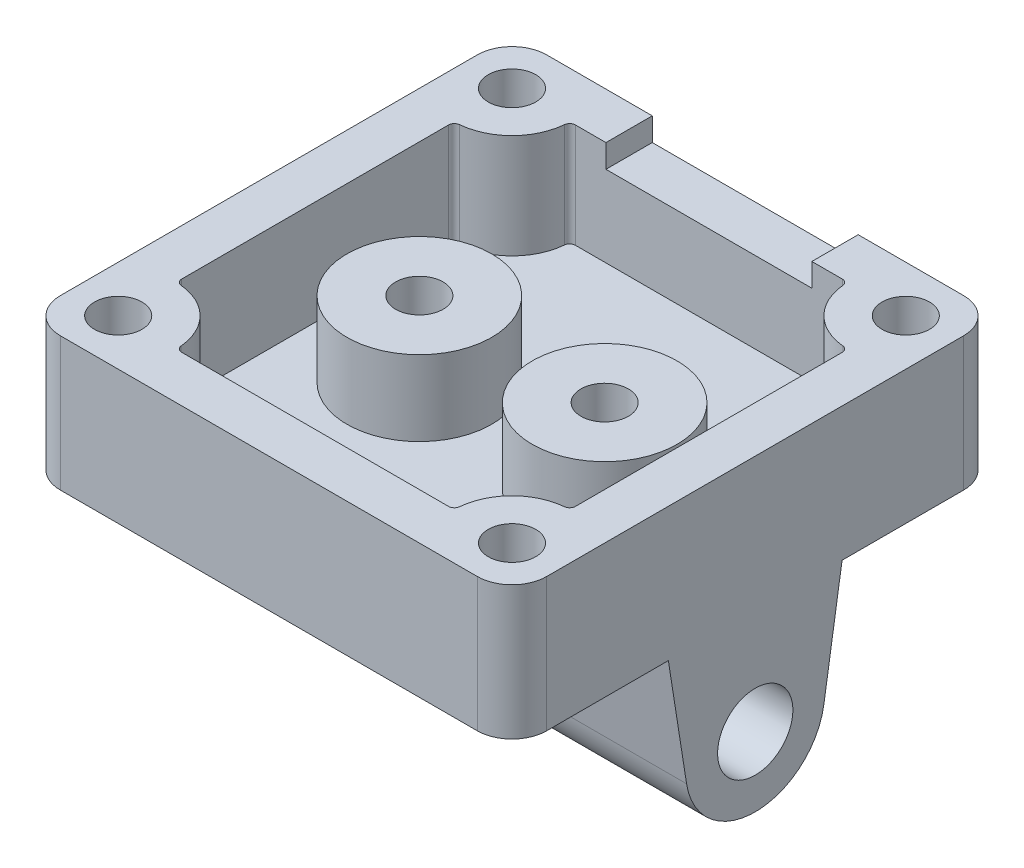
from build123d import *

# Parameters (mm, degrees)
SKETCH1_W           = 42
SKETCH1_H           = 42
BOSS_EXTRUDE1_DEPTH = 2.54
SKETCH2_W           = 42
SKETCH2_H           = 42
BOSS_EXTRUDE2_DEPTH = 9
SKETCH4_R           = 3.25
BOSS_EXTRUDE4_DEPTH = 42
SKETCH9_R           = 6.25
SKETCH9_R_2         = 2.05
BOSS_EXTRUDE5_DEPTH = 6.5
SKETCH10_R          = 2.05
CUT_EXTRUDE1_DEPTH  = 8
SKETCH12_W          = 17.78
SKETCH12_H          = 2
CUT_EXTRUDE2_DEPTH  = 4
FILLET1_R           = 3


with BuildPart() as part:
    # Sketch1 → Boss-Extrude1 (new body)
    with BuildSketch(Plane(origin=(0, 0, 0), x_dir=(1, 0, 0), z_dir=(0, 1, 0))):
        Rectangle(SKETCH1_W, SKETCH1_H)
    extrude(amount=BOSS_EXTRUDE1_DEPTH)

    # Sketch2 → Boss-Extrude2 (add)
    with BuildSketch(Plane(origin=(0, 2.54, 0), x_dir=(1, 0, 0), z_dir=(0, 1, 0))):
        Rectangle(SKETCH2_W, SKETCH2_H)
        with BuildLine():
            Line((-17, 11.522774425), (-17, -11.522774425))
            ThreePointArc((-17, -11.522774425), (-16.869274473, -11.859874356), (-16.545454545, -12.020704023))
            ThreePointArc((-16.545454545, -12.020704023), (-13.464466094, -13.464466094), (-12.020704023, -16.545454545))
            ThreePointArc((-12.020704023, -16.545454545), (-11.859874356, -16.869274473), (-11.522774425, -17))
            Line((-11.522774425, -17), (11.522774425, -17))
            ThreePointArc((11.522774425, -17), (11.859874356, -16.869274473), (12.020704023, -16.545454545))
            ThreePointArc((12.020704023, -16.545454545), (13.464466094, -13.464466094), (16.545454545, -12.020704023))
            ThreePointArc((16.545454545, -12.020704023), (16.869274473, -11.859874356), (17, -11.522774425))
            Line((17, -11.522774425), (17, 11.522774425))
            ThreePointArc((17, 11.522774425), (16.869274473, 11.859874356), (16.545454545, 12.020704023))
            ThreePointArc((16.545454545, 12.020704023), (13.464466094, 13.464466094), (12.020704023, 16.545454545))
            ThreePointArc((12.020704023, 16.545454545), (11.859874356, 16.869274473), (11.522774425, 17))
            Line((11.522774425, 17), (-11.522774425, 17))
            ThreePointArc((-11.522774425, 17), (-11.859874356, 16.869274473), (-12.020704023, 16.545454545))
            ThreePointArc((-12.020704023, 16.545454545), (-13.464466094, 13.464466094), (-16.545454545, 12.020704023))
            ThreePointArc((-16.545454545, 12.020704023), (-16.869274473, 11.859874356), (-17, 11.522774425))
        make_face(mode=Mode.SUBTRACT)
    extrude(amount=BOSS_EXTRUDE2_DEPTH)

    # Sketch4 → Boss-Extrude4 (add)
    with BuildSketch(Plane.ZY.offset(21)):
        with BuildLine():
            Line((7.5, 0), (5.927131841, -10))
            ThreePointArc((5.927131841, -10), (0, -15.067740305), (-5.927131841, -10))
            Line((-5.927131841, -10), (-7.5, 0))
            Line((-7.5, 0), (7.5, 0))
        make_face()
        with Locations((0, -9.067740305)):
            Circle(SKETCH4_R, mode=Mode.SUBTRACT)
    extrude(amount=-BOSS_EXTRUDE4_DEPTH)

    # Sketch9 → Boss-Extrude5 (add)
    with BuildSketch(Plane(origin=(0, 2.54, 0), x_dir=(1, 0, 0), z_dir=(0, 1, 0))):
        with Locations((8, 0)):
            Circle(SKETCH9_R)
        with Locations((8, 0)):
            Circle(SKETCH9_R_2, mode=Mode.SUBTRACT)
        with Locations((-8, 0)):
            Circle(SKETCH9_R)
        with Locations((-8, 0)):
            Circle(SKETCH9_R_2, mode=Mode.SUBTRACT)
    extrude(amount=BOSS_EXTRUDE5_DEPTH)

    # Sketch10 → Cut-Extrude1 (cut)
    with BuildSketch(Plane(origin=(0, 11.54, 0), x_dir=(1, 0, 0), z_dir=(0, 1, 0))):
        with Locations((-17, 17)):
            Circle(SKETCH10_R)
        with Locations((17, 17)):
            Circle(SKETCH10_R)
        with Locations((-17, -17)):
            Circle(SKETCH10_R)
        with Locations((17, -17)):
            Circle(SKETCH10_R)
    extrude(amount=-CUT_EXTRUDE1_DEPTH, mode=Mode.SUBTRACT)

    # Sketch12 → Cut-Extrude2 (cut)
    with BuildSketch(Plane(origin=(0, 0, -21), x_dir=(-1, 0, 0), z_dir=(0, 0, -1))):
        with Locations((0, 10.54)):
            Rectangle(SKETCH12_W, SKETCH12_H)
    extrude(amount=-CUT_EXTRUDE2_DEPTH, mode=Mode.SUBTRACT)

    # Fillet1
    fillet1_edges = [part.edges().sort_by_distance(p)[0] for p in [
        (21, 5.77, 21),
        (-21, 5.77, 21),
        (-21, 5.77, -21),
        (21, 5.77, -21),
    ]]
    fillet(fillet1_edges, radius=FILLET1_R)


solid = part.part
